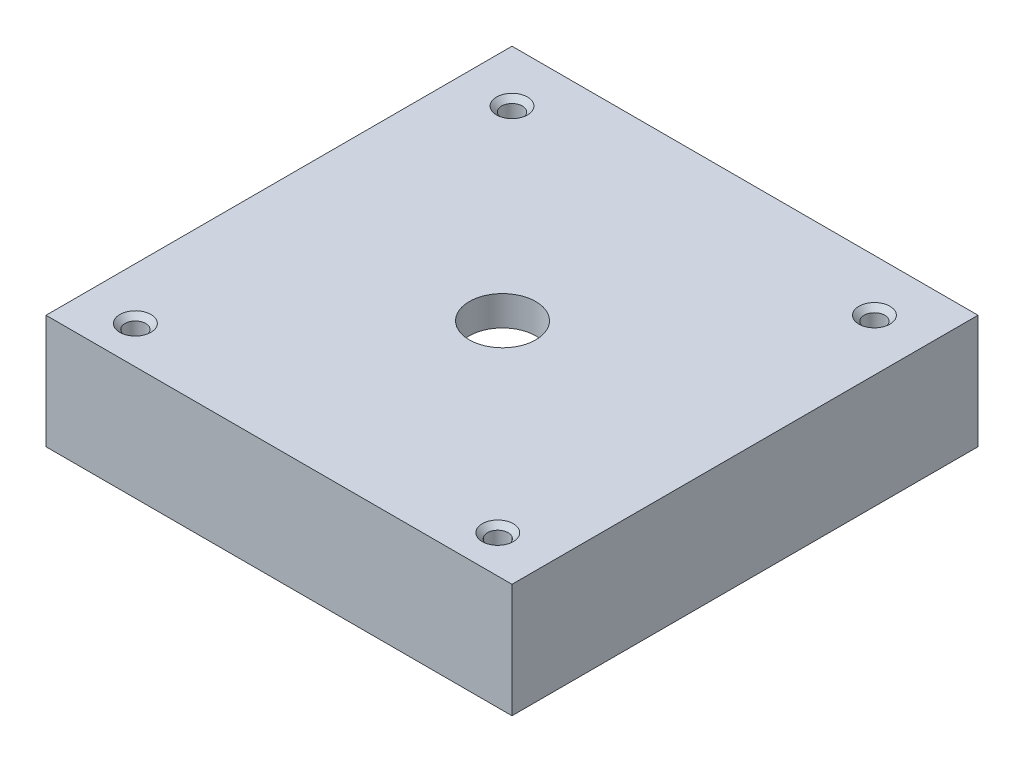
from build123d import *

# Parameters (mm, degrees)
SKETCH1_W               = 90
SKETCH1_H               = 90.01
BOSS_EXTRUDE1_DEPTH     = 22
SKETCH2_R               = 2
CUT_EXTRUDE1_DEPTH      = 1
CUT_EXTRUDE1_DEPTH_BACK = 23
CUT_EXTRUDE2_DEPTH      = 16.25
SKETCH4_R               = 6.416854585
CUT_EXTRUDE3_DEPTH      = 6.75
CHAMFER1_SIZE           = 1


with BuildPart() as part:
    # Sketch1 → Boss-Extrude1 (new body)
    with BuildSketch(Plane(origin=(0, 0, 0), x_dir=(1, 0, 0), z_dir=(0, 1, 0))):
        with Locations((45, 45.005)):
            Rectangle(SKETCH1_W, SKETCH1_H)
    extrude(amount=BOSS_EXTRUDE1_DEPTH)

    # Sketch2 → Cut-Extrude1 (cut, two sides)
    with BuildSketch(Plane.XZ) as cut_extrude1_sk:
        with Locations((9.997, -7.265579483)):
            Circle(SKETCH2_R)
        with Locations((9.997, -80.01)):
            Circle(SKETCH2_R)
        with Locations((79.997, -7.265579483)):
            Circle(SKETCH2_R)
        with Locations((79.997, -80.01)):
            Circle(SKETCH2_R)
    extrude(amount=CUT_EXTRUDE1_DEPTH, mode=Mode.SUBTRACT)
    extrude(cut_extrude1_sk.sketch, amount=-CUT_EXTRUDE1_DEPTH_BACK, mode=Mode.SUBTRACT)

    # Sketch3 → Cut-Extrude2 (cut)
    with BuildSketch(Plane.XZ):
        with BuildLine():
            Line((26.092808525, -11.764178956), (63.899808525, -11.764178956))
            ThreePointArc((63.899808525, -11.764178956), (82.022370223, -22.681759768), (80.842050765, -43.805861151))
            Line((80.842050765, -43.805861151), (62.765845791, -75.228209836))
            ThreePointArc((62.765845791, -75.228209836), (45.012346751, -85.505995123), (27.242787748, -75.256001397))
            Line((27.242787748, -75.256001397), (8.339287748, -42.514178956))
            ThreePointArc((8.339287748, -42.514178956), (8.339287748, -22.014178956), (26.092808525, -11.764178956))
        make_face()
    extrude(amount=-CUT_EXTRUDE2_DEPTH, mode=Mode.SUBTRACT)

    # Sketch4 → Cut-Extrude3 (cut, through all)
    with BuildSketch(Plane.XZ.offset(-16.25)):
        with Locations((44.996308525, -43.17811977)):
            Circle(SKETCH4_R)
    extrude(amount=-CUT_EXTRUDE3_DEPTH, mode=Mode.SUBTRACT)

    # Chamfer1
    chamfer1_edges = [part.edges().sort_by_distance(p)[0] for p in [
        (7.997, 22, -7.265579483),
        (7.997, 22, -80.01),
        (77.997, 22, -7.265579483),
        (77.997, 22, -80.01),
    ]]
    chamfer(chamfer1_edges, length=CHAMFER1_SIZE)


solid = part.part
